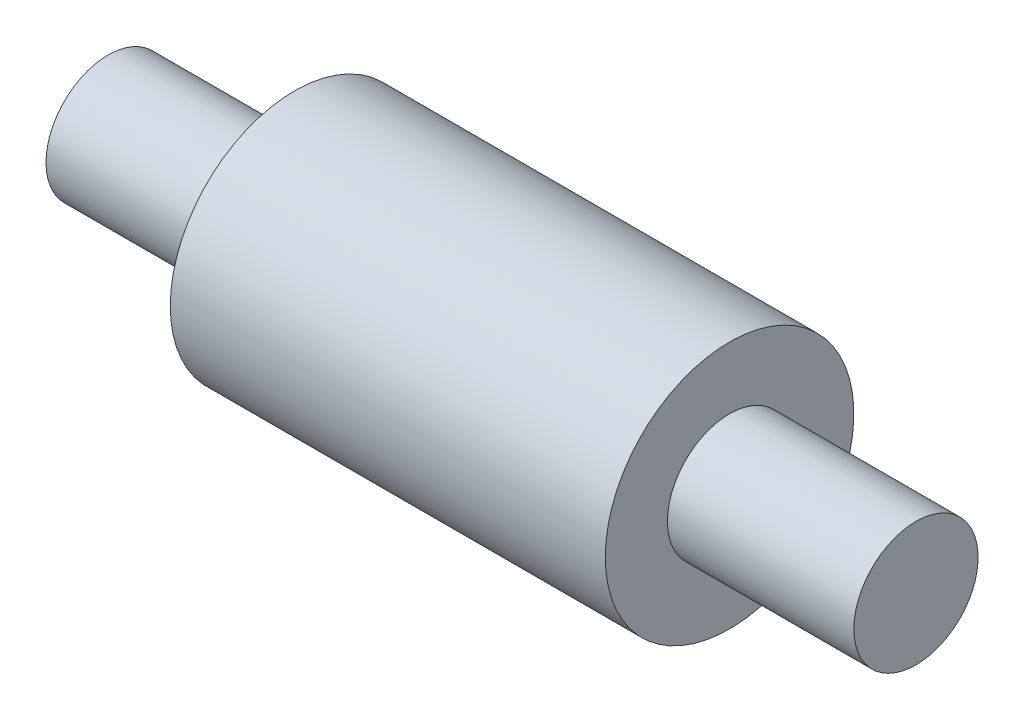
from build123d import *


with BuildPart() as part:
    # Sketch1 → Revolve2 (revolve)
    with BuildSketch(Plane.XY):
        Polygon((0, 0), (0, 10), (30, 10), (30, 20), (100, 20), (100, 10), (130, 10), (130, 0), align=None)
    revolve(axis=Axis((-58.418248255, 0, 0), (1, 0, 0)))


solid = part.part
